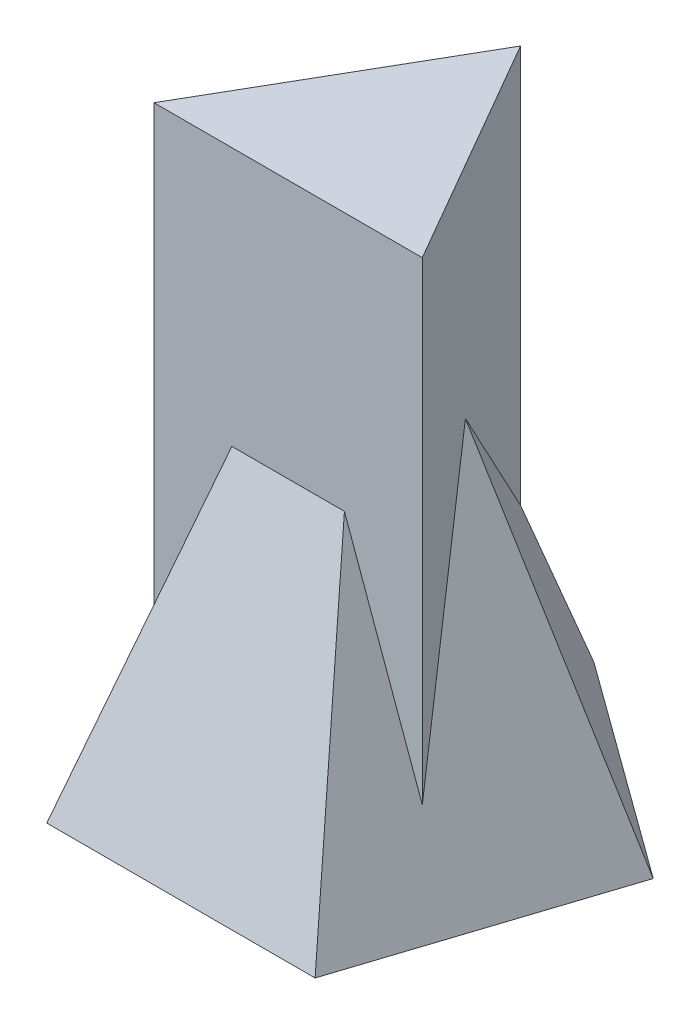
from build123d import *

# Parameters (mm, degrees)
TRIANGULAR_PRISM_DEPTH = 85


with BuildPart() as part:
    # Sketch1 → Pyramid section 0
    with BuildSketch(Plane(origin=(0, 0, 0), x_dir=(1, 0, 0), z_dir=(0, 1, 0)), mode=Mode.PRIVATE) as pyramid_s0:
        Polygon((20, -27.527638409), (32.360679775, 10.514622242), (0, 34.026032334), (-32.360679775, 10.514622242), (-20, -27.527638409), align=None)
    loft([Vertex(0, 80, 0), pyramid_s0.sketch])

    # Sketch3 → Triangular prism (add)
    with BuildSketch(Plane(origin=(0, 0, 0), x_dir=(1, 0, 0), z_dir=(0, 1, 0))):
        Polygon((20, -11.547005384), (0, 23.094010768), (-20, -11.547005384), align=None)
    extrude(amount=TRIANGULAR_PRISM_DEPTH)


solid = part.part
